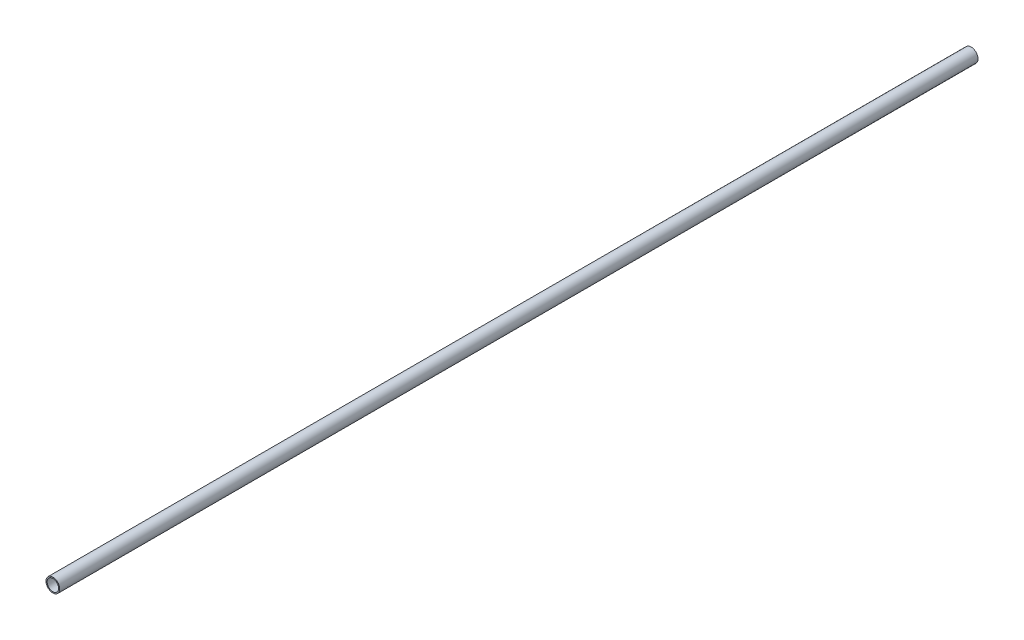
from build123d import *

# Parameters (mm, degrees)
SKETCH1_R           = 6
SKETCH1_R_2         = 5
BOSS_EXTRUDE1_DEPTH = 800


with BuildPart() as part:
    # Sketch1 → Boss-Extrude1 (new body)
    with BuildSketch(Plane.XY):
        Circle(SKETCH1_R)
        Circle(SKETCH1_R_2, mode=Mode.SUBTRACT)
    extrude(amount=BOSS_EXTRUDE1_DEPTH)


solid = part.part
